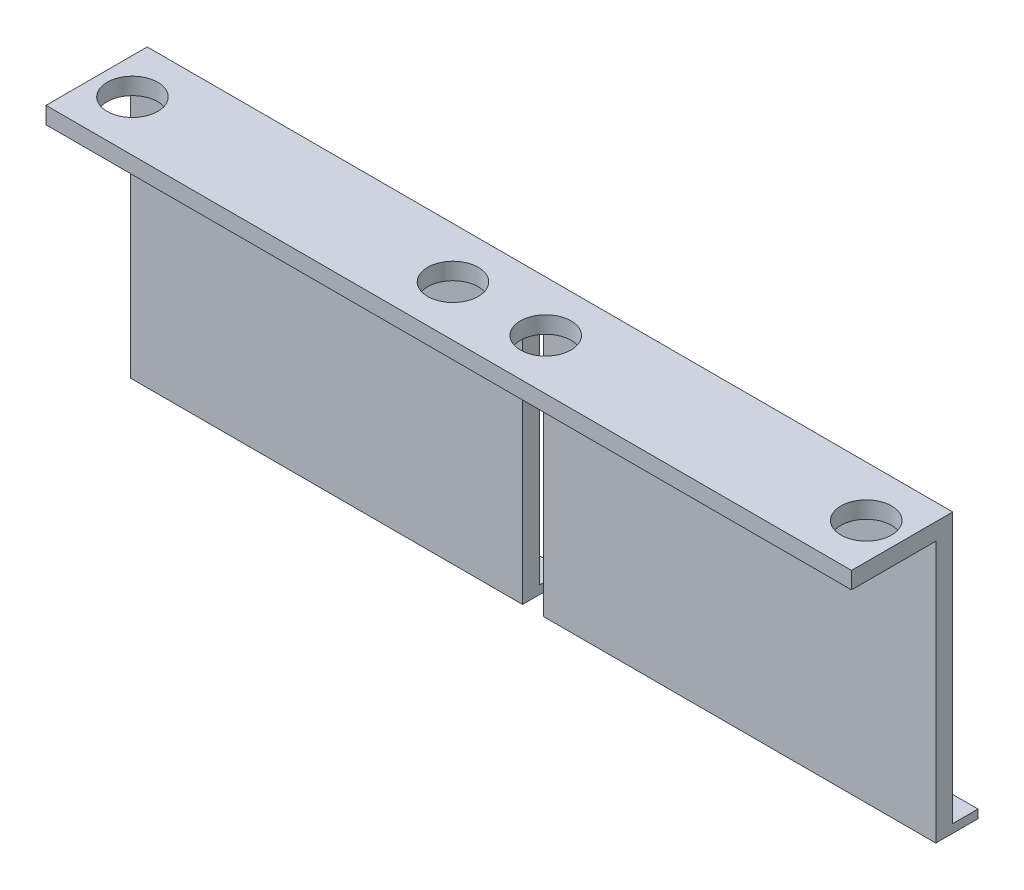
from build123d import *

# Parameters (mm, degrees)
BOSS_EXTRUDE1_DEPTH = 2
SKETCH2_W           = 95.5
SKETCH2_H           = 2
BOSS_EXTRUDE2_DEPTH = 10
SKETCH3_R           = 3
CUT_EXTRUDE1_DEPTH  = 34
SKETCH4_W           = 46.5
SKETCH4_H           = 1
BOSS_EXTRUDE3_DEPTH = 3


with BuildPart() as part:
    # Sketch1 → Boss-Extrude1 (new body)
    with BuildSketch(Plane.XY):
        Polygon((-2.998624877, 17.747280284), (-0.498624877, 17.747280284), (-0.498624877, -11.252719716), (46.001375123, -11.252719716), (46.001375123, 21.747280284), (-49.498624877, 21.747280284), (-49.498624877, -11.252719716), (-2.998624877, -11.252719716), align=None)
    extrude(amount=BOSS_EXTRUDE1_DEPTH)

    # Sketch2 → Boss-Extrude2 (add)
    with BuildSketch(Plane.XY.offset(2)):
        with Locations((-1.748624877, 20.747280284)):
            Rectangle(SKETCH2_W, SKETCH2_H)
    extrude(amount=BOSS_EXTRUDE2_DEPTH)

    # Sketch3 → Cut-Extrude1 (cut, through all)
    with BuildSketch(Plane(origin=(0, 21.747280284, 0), x_dir=(1, 0, 0), z_dir=(0, 1, 0))):
        with Locations((-45.248624877, -6)):
            Circle(SKETCH3_R)
        with Locations((-7.248624877, -6)):
            Circle(SKETCH3_R)
        with Locations((3.751375123, -6)):
            Circle(SKETCH3_R)
        with Locations((41.751375123, -6)):
            Circle(SKETCH3_R)
    extrude(amount=-CUT_EXTRUDE1_DEPTH, mode=Mode.SUBTRACT)

    # Sketch4 → Boss-Extrude3 (add)
    with BuildSketch(Plane(origin=(0, 0, 0), x_dir=(-1, 0, 0), z_dir=(0, 0, -1))):
        with Locations((-22.751375123, -10.752719716)):
            Rectangle(SKETCH4_W, SKETCH4_H)
        with Locations((26.248624877, -10.752719716)):
            Rectangle(SKETCH4_W, SKETCH4_H)
    extrude(amount=BOSS_EXTRUDE3_DEPTH)


solid = part.part
